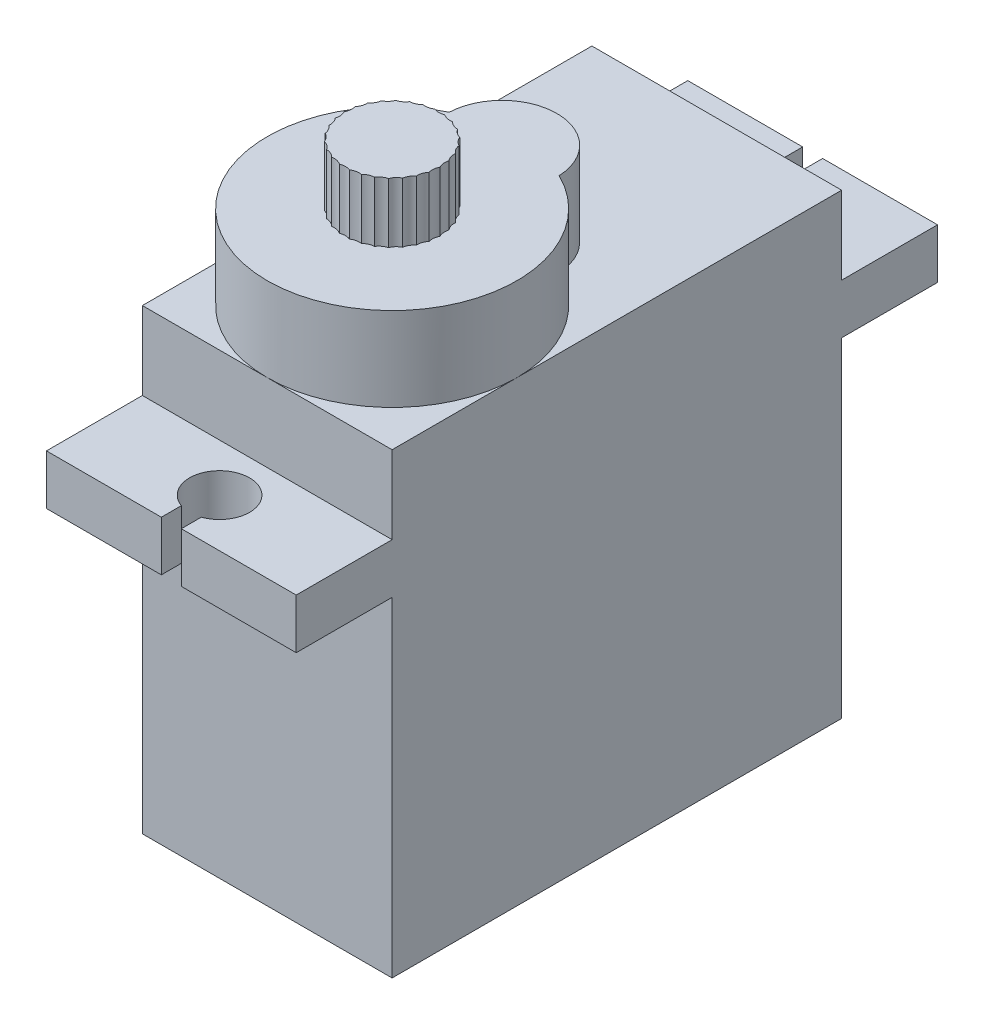
from build123d import *

# Parameters (mm, degrees)
SKETCH1_W           = 12.5
SKETCH1_H           = 22.5
BOSS_EXTRUDE1_DEPTH = 19
SKETCH2_W           = 12.5
SKETCH2_H           = 32.1
BOSS_EXTRUDE2_DEPTH = 2.5
SKETCH3_W           = 12.5
SKETCH3_H           = 22.5
BOSS_EXTRUDE3_DEPTH = 3.9
BOSS_EXTRUDE4_DEPTH = 4.2
BOSS_EXTRUDE5_DEPTH = 3
CUT_EXTRUDE1_DEPTH  = 20


with BuildPart() as part:
    # Sketch1 → Boss-Extrude1 (new body)
    with BuildSketch(Plane(origin=(0, 0, 0), x_dir=(1, 0, 0), z_dir=(0, 1, 0))):
        Rectangle(SKETCH1_W, SKETCH1_H)
    extrude(amount=BOSS_EXTRUDE1_DEPTH)

    # Sketch2 → Boss-Extrude2 (add)
    with BuildSketch(Plane(origin=(0, 19, 0), x_dir=(1, 0, 0), z_dir=(0, 1, 0))):
        Rectangle(SKETCH2_W, SKETCH2_H)
    extrude(amount=-BOSS_EXTRUDE2_DEPTH)

    # Sketch3 → Boss-Extrude3 (add)
    with BuildSketch(Plane(origin=(0, 19, 0), x_dir=(1, 0, 0), z_dir=(0, 1, 0))):
        Rectangle(SKETCH3_W, SKETCH3_H)
    extrude(amount=BOSS_EXTRUDE3_DEPTH)

    # Sketch4 → Boss-Extrude4 (add)
    with BuildSketch(Plane(origin=(0, 22.9, 0), x_dir=(1, 0, 0), z_dir=(0, 1, 0))):
        with BuildLine():
            ThreePointArc((-2.75, 0.61248608), (0, -11.25), (2.75, 0.61248608))
            ThreePointArc((2.75, 0.61248608), (0, 3.25), (-2.75, 0.61248608))
        make_face()
    extrude(amount=BOSS_EXTRUDE4_DEPTH)

    # Sketch5 → Boss-Extrude5 (add)
    with BuildSketch(Plane(origin=(0, 27.1, 0), x_dir=(1, 0, 0), z_dir=(0, 1, 0))):
        with BuildLine():
            ThreePointArc((-0.25, -2.613056348), (-0.250868312, -2.613147451), (-0.25173659, -2.613238871))
            ThreePointArc((-0.25173659, -2.613238871), (-0.485877906, -2.714124173), (-0.740810391, -2.717194716))
            ThreePointArc((-0.740810391, -2.717194716), (-0.741640786, -2.717464361), (-0.742471084, -2.717734308))
            ThreePointArc((-0.742471084, -2.717734308), (-0.950520616, -2.865095742), (-1.199243813, -2.921102629))
            ThreePointArc((-1.199243813, -2.921102629), (-1.2, -2.921539031), (-1.200756028, -2.921975707))
            ThreePointArc((-1.200756028, -2.921975707), (-1.373621014, -3.10937287), (-1.605264526, -3.215868334))
            ThreePointArc((-1.605264526, -3.215868334), (-1.605913455, -3.216452419), (-1.606562172, -3.21703674))
            ThreePointArc((-1.606562172, -3.21703674), (-1.736687583, -3.436279477), (-1.941127476, -3.588609153))
            ThreePointArc((-1.941127476, -3.588609153), (-1.941640786, -3.589315394), (-1.94215384, -3.590021823))
            ThreePointArc((-1.94215384, -3.590021823), (-2.02385257, -3.831528174), (-2.19215384, -4.023034525))
            ThreePointArc((-2.19215384, -4.023034525), (-2.192509098, -4.023832057), (-2.192864066, -4.024629718))
            ThreePointArc((-2.192864066, -4.024629718), (-2.222565489, -4.277844696), (-2.347372563, -4.500157976))
            ThreePointArc((-2.347372563, -4.500157976), (-2.347554242, -4.501011942), (-2.34773561, -4.501865974))
            ThreePointArc((-2.34773561, -4.501865974), (-2.324141631, -4.755722871), (-2.399999841, -4.999126922))
            ThreePointArc((-2.399999841, -4.999126922), (-2.4, -5), (-2.399999841, -5.000873078))
            ThreePointArc((-2.399999841, -5.000873078), (-2.324141631, -5.244277129), (-2.34773561, -5.498134026))
            ThreePointArc((-2.34773561, -5.498134026), (-2.347554242, -5.498988058), (-2.347372563, -5.499842024))
            ThreePointArc((-2.347372563, -5.499842024), (-2.222565489, -5.722155304), (-2.192864066, -5.975370282))
            ThreePointArc((-2.192864066, -5.975370282), (-2.192509098, -5.976167943), (-2.19215384, -5.976965475))
            ThreePointArc((-2.19215384, -5.976965475), (-2.02385257, -6.168471826), (-1.94215384, -6.409978177))
            ThreePointArc((-1.94215384, -6.409978177), (-1.941640786, -6.410684606), (-1.941127476, -6.411390847))
            ThreePointArc((-1.941127476, -6.411390847), (-1.736687583, -6.563720523), (-1.606562172, -6.78296326))
            ThreePointArc((-1.606562172, -6.78296326), (-1.605913455, -6.783547581), (-1.605264526, -6.784131666))
            ThreePointArc((-1.605264526, -6.784131666), (-1.373621014, -6.89062713), (-1.200756028, -7.078024293))
            ThreePointArc((-1.200756028, -7.078024293), (-1.2, -7.078460969), (-1.199243813, -7.078897371))
            ThreePointArc((-1.199243813, -7.078897371), (-0.950520616, -7.134904258), (-0.742471084, -7.282265692))
            ThreePointArc((-0.742471084, -7.282265692), (-0.741640786, -7.282535639), (-0.740810391, -7.282805284))
            ThreePointArc((-0.740810391, -7.282805284), (-0.485877906, -7.285875827), (-0.25173659, -7.386761129))
            ThreePointArc((-0.25173659, -7.386761129), (-0.250868312, -7.386852549), (-0.25, -7.386943652))
            ThreePointArc((-0.25, -7.386943652), (0, -7.336943652), (0.25, -7.386943652))
            ThreePointArc((0.25, -7.386943652), (0.250868312, -7.386852549), (0.25173659, -7.386761129))
            ThreePointArc((0.25173659, -7.386761129), (0.485877906, -7.285875827), (0.740810391, -7.282805284))
            ThreePointArc((0.740810391, -7.282805284), (0.741640786, -7.282535639), (0.742471084, -7.282265692))
            ThreePointArc((0.742471084, -7.282265692), (0.950520616, -7.134904258), (1.199243813, -7.078897371))
            ThreePointArc((1.199243813, -7.078897371), (1.2, -7.078460969), (1.200756028, -7.078024293))
            ThreePointArc((1.200756028, -7.078024293), (1.373621014, -6.89062713), (1.605264526, -6.784131666))
            ThreePointArc((1.605264526, -6.784131666), (1.605913455, -6.783547581), (1.606562172, -6.78296326))
            ThreePointArc((1.606562172, -6.78296326), (1.736687583, -6.563720523), (1.941127476, -6.411390847))
            ThreePointArc((1.941127476, -6.411390847), (1.941640786, -6.410684606), (1.94215384, -6.409978177))
            ThreePointArc((1.94215384, -6.409978177), (2.02385257, -6.168471826), (2.19215384, -5.976965475))
            ThreePointArc((2.19215384, -5.976965475), (2.192509098, -5.976167943), (2.192864066, -5.975370282))
            ThreePointArc((2.192864066, -5.975370282), (2.222565489, -5.722155304), (2.347372563, -5.499842024))
            ThreePointArc((2.347372563, -5.499842024), (2.347554242, -5.498988058), (2.34773561, -5.498134026))
            ThreePointArc((2.34773561, -5.498134026), (2.324141631, -5.244277129), (2.399999841, -5.000873078))
            ThreePointArc((2.399999841, -5.000873078), (2.4, -5), (2.399999841, -4.999126922))
            ThreePointArc((2.399999841, -4.999126922), (2.324141631, -4.755722871), (2.34773561, -4.501865974))
            ThreePointArc((2.34773561, -4.501865974), (2.347554242, -4.501011942), (2.347372563, -4.500157976))
            ThreePointArc((2.347372563, -4.500157976), (2.222565489, -4.277844696), (2.192864066, -4.024629718))
            ThreePointArc((2.192864066, -4.024629718), (2.192509098, -4.023832057), (2.19215384, -4.023034525))
            ThreePointArc((2.19215384, -4.023034525), (2.02385257, -3.831528174), (1.94215384, -3.590021823))
            ThreePointArc((1.94215384, -3.590021823), (1.941640786, -3.589315394), (1.941127476, -3.588609153))
            ThreePointArc((1.941127476, -3.588609153), (1.736687583, -3.436279477), (1.606562172, -3.21703674))
            ThreePointArc((1.606562172, -3.21703674), (1.605913455, -3.216452419), (1.605264526, -3.215868334))
            ThreePointArc((1.605264526, -3.215868334), (1.373621014, -3.10937287), (1.200756028, -2.921975707))
            ThreePointArc((1.200756028, -2.921975707), (1.2, -2.921539031), (1.199243813, -2.921102629))
            ThreePointArc((1.199243813, -2.921102629), (0.950520616, -2.865095742), (0.742471084, -2.717734308))
            ThreePointArc((0.742471084, -2.717734308), (0.741640786, -2.717464361), (0.740810391, -2.717194716))
            ThreePointArc((0.740810391, -2.717194716), (0.485877906, -2.714124173), (0.25173659, -2.613238871))
            ThreePointArc((0.25173659, -2.613238871), (0.250868312, -2.613147451), (0.25, -2.613056348))
            ThreePointArc((0.25, -2.613056348), (0, -2.663056348), (-0.25, -2.613056348))
        make_face()
    extrude(amount=BOSS_EXTRUDE5_DEPTH)

    # Sketch6 → Cut-Extrude1 (cut, through all)
    with BuildSketch(Plane(origin=(0, 19, 0), x_dir=(1, 0, 0), z_dir=(0, 1, 0))):
        with BuildLine():
            Line((0.5, 16.05), (0.5, 15.05))
            ThreePointArc((0.5, 15.05), (0, 12.135786438), (-0.5, 15.05))
            Line((-0.5, 15.05), (-0.5, 16.05))
            Line((-0.5, 16.05), (0.5, 16.05))
        make_face()
        with BuildLine():
            Line((-0.5, -16.05), (-0.5, -15.05))
            ThreePointArc((-0.5, -15.05), (0, -12.135786438), (0.5, -15.05))
            Line((0.5, -15.05), (0.5, -16.05))
            Line((0.5, -16.05), (-0.5, -16.05))
        make_face()
    extrude(amount=-CUT_EXTRUDE1_DEPTH, mode=Mode.SUBTRACT)


solid = part.part
